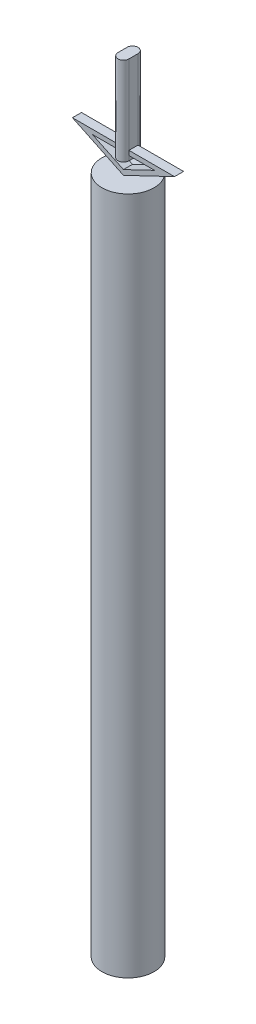
from build123d import *

# Parameters (mm, degrees)
SKETCH2_R                = 11.5
BOSS_EXTRUDE1_DEPTH      = 300
BOSS_EXTRUDE2_DEPTH      = 2
BOSS_EXTRUDE2_DEPTH_BACK = 2
BOSS_EXTRUDE5_DEPTH      = 35
BOSS_EXTRUDE5_DEPTH_BACK = 4


with BuildPart() as part:
    # Sketch2 → Boss-Extrude1 (new body)
    with BuildSketch(Plane(origin=(0, 0, 0), x_dir=(1, 0, 0), z_dir=(0, 1, 0))):
        Circle(SKETCH2_R)
    extrude(amount=BOSS_EXTRUDE1_DEPTH)


with BuildPart() as body_2:
    # Sketch3 → Boss-Extrude2 (new, two sides: drawn at the far end of the back side and taken through both)
    with BuildSketch(Plane.XY.offset(-BOSS_EXTRUDE2_DEPTH_BACK)):
        Polygon((0, 300), (-22.556872792, 310.779030097), (22.556872792, 310.779030097), align=None)
        Polygon((0, 302.216619319), (-13.732911385, 308.779030097), (13.732911385, 308.779030097), align=None, mode=Mode.SUBTRACT)
    extrude(amount=BOSS_EXTRUDE2_DEPTH + BOSS_EXTRUDE2_DEPTH_BACK)

    # Sketch6 → Boss-Extrude5 (add, two sides: drawn at the far end of the back side and taken through both)
    with BuildSketch(Plane(origin=(0, 310.779030097, 0), x_dir=(1, 0, 0), z_dir=(0, 1, 0)).offset(-BOSS_EXTRUDE5_DEPTH_BACK)):
        with BuildLine():
            Line((2.426445001, 2), (2.426445001, -2))
            ThreePointArc((2.426445001, -2), (0, -4.426445001), (-2.426445001, -2))
            Line((-2.426445001, -2), (-2.426445001, 2))
            ThreePointArc((-2.426445001, 2), (0, 4.426445001), (2.426445001, 2))
        make_face()
    extrude(amount=BOSS_EXTRUDE5_DEPTH + BOSS_EXTRUDE5_DEPTH_BACK)


solid = Compound([part.part, body_2.part])
